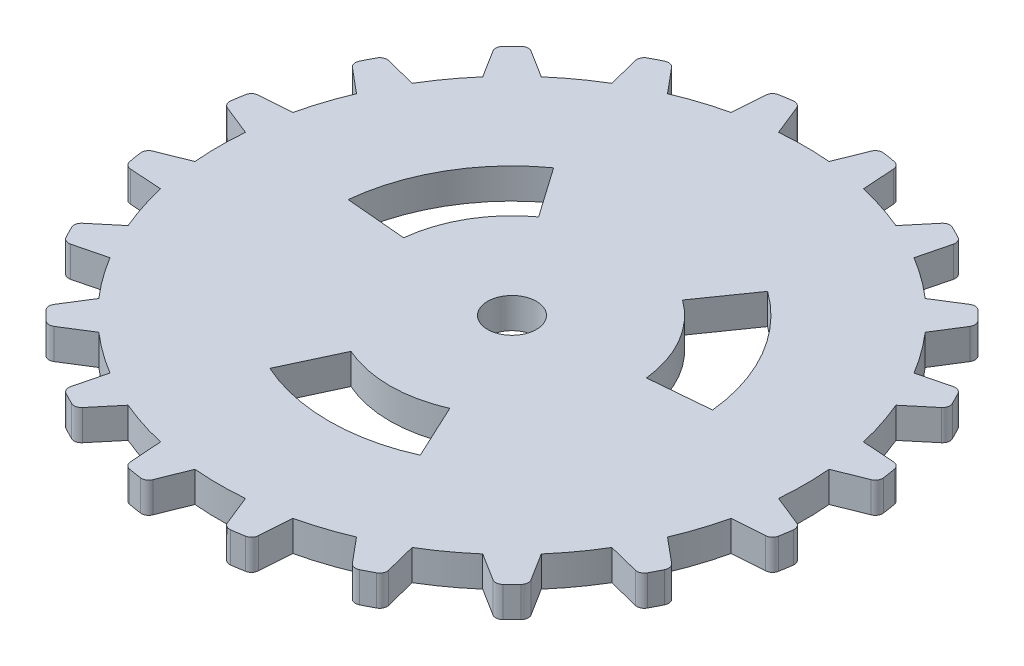
from build123d import *

# Parameters (mm, degrees)
BOSS_EXTRUDE1_DEPTH = 2.5
FILLET1_R           = 0.6
SKETCH3_R           = 2
CUT_EXTRUDE2_DEPTH  = 3.5
CUT_EXTRUDE3_DEPTH  = 10


with BuildPart() as part:
    # Sketch1 → Boss-Extrude1 (new body)
    with BuildSketch(Plane(origin=(0, 0, 0), x_dir=(1, 0, 0), z_dir=(0, 1, 0))):
        with BuildLine():
            Line((-2.069685574, 23.903244449), (-3.232226288, 26.798460531))
            ThreePointArc((-3.232226288, 26.798460531), (-4.222590109, 26.66035458), (-5.207159099, 26.485661549))
            Line((-5.207159099, 26.485661549), (-5.418128963, 23.372902518))
            ThreePointArc((-5.418128963, 23.372902518), (-7.414149843, 22.818393363), (-9.354896707, 22.093768379))
            Line((-9.354896707, 22.093768379), (-11.3552096, 24.488037662))
            ThreePointArc((-11.3552096, 24.488037662), (-12.25442448, 24.050651847), (-13.136822119, 23.580260351))
            Line((-13.136822119, 23.580260351), (-12.375570942, 20.554657318))
            ThreePointArc((-12.375570942, 20.554657318), (-14.102546855, 19.410483399), (-15.724385372, 18.121600323))
            Line((-15.724385372, 18.121600323), (-18.36666588, 19.780555048))
            ThreePointArc((-18.36666588, 19.780555048), (-19.086710402, 19.086703739), (-19.78056146, 18.366658976))
            Line((-19.78056146, 18.366658976), (-18.121605812, 15.724379046))
            ThreePointArc((-18.121605812, 15.724379046), (-19.410488322, 14.102540079), (-20.554661637, 12.375563767))
            Line((-20.554661637, 12.375563767), (-23.580264936, 13.136813888))
            ThreePointArc((-23.580264936, 13.136813888), (-24.050656124, 12.254416085), (-24.488041625, 11.355201052))
            Line((-24.488041625, 11.355201052), (-22.093771644, 9.354888995))
            ThreePointArc((-22.093771644, 9.354888995), (-22.818395951, 7.414141878), (-23.37290441, 5.418120804))
            Line((-23.37290441, 5.418120804), (-26.485663367, 5.207149854))
            ThreePointArc((-26.485663367, 5.207149854), (-26.660356054, 4.222580803), (-26.798461659, 3.232216933))
            Line((-26.798461659, 3.232216933), (-23.903245172, 2.06967723))
            ThreePointArc((-23.903245172, 2.06967723), (-23.99268, -4.188e-06), (-23.903244449, -2.069685574))
            Line((-23.903244449, -2.069685574), (-26.798460531, -3.232226288))
            ThreePointArc((-26.798460531, -3.232226288), (-26.66035458, -4.222590109), (-26.485661549, -5.207159099))
            Line((-26.485661549, -5.207159099), (-23.372902518, -5.418128963))
            ThreePointArc((-23.372902518, -5.418128963), (-22.818393363, -7.414149843), (-22.093768379, -9.354896707))
            Line((-22.093768379, -9.354896707), (-24.488037662, -11.3552096))
            ThreePointArc((-24.488037662, -11.3552096), (-24.050651847, -12.25442448), (-23.580260351, -13.136822119))
            Line((-23.580260351, -13.136822119), (-20.554657318, -12.375570942))
            ThreePointArc((-20.554657318, -12.375570942), (-19.410483399, -14.102546855), (-18.121600323, -15.724385372))
            Line((-18.121600323, -15.724385372), (-19.780555048, -18.36666588))
            ThreePointArc((-19.780555048, -18.36666588), (-19.086703739, -19.086710402), (-18.366658976, -19.78056146))
            Line((-18.366658976, -19.78056146), (-15.724379046, -18.121605812))
            ThreePointArc((-15.724379046, -18.121605812), (-14.102540079, -19.410488322), (-12.375563767, -20.554661637))
            Line((-12.375563767, -20.554661637), (-13.136813888, -23.580264936))
            ThreePointArc((-13.136813888, -23.580264936), (-12.254416085, -24.050656124), (-11.355201052, -24.488041625))
            Line((-11.355201052, -24.488041625), (-9.354888995, -22.093771644))
            ThreePointArc((-9.354888995, -22.093771644), (-7.414141878, -22.818395951), (-5.418120804, -23.37290441))
            Line((-5.418120804, -23.37290441), (-5.207149854, -26.485663367))
            ThreePointArc((-5.207149854, -26.485663367), (-4.222580803, -26.660356054), (-3.232216933, -26.798461659))
            Line((-3.232216933, -26.798461659), (-2.06967723, -23.903245172))
            ThreePointArc((-2.06967723, -23.903245172), (4.188e-06, -23.99268), (2.069685574, -23.903244449))
            Line((2.069685574, -23.903244449), (3.232226288, -26.798460531))
            ThreePointArc((3.232226288, -26.798460531), (4.222590109, -26.66035458), (5.207159099, -26.485661549))
            Line((5.207159099, -26.485661549), (5.418128963, -23.372902518))
            ThreePointArc((5.418128963, -23.372902518), (7.414149843, -22.818393363), (9.354896707, -22.093768379))
            Line((9.354896707, -22.093768379), (11.3552096, -24.488037662))
            ThreePointArc((11.3552096, -24.488037662), (12.25442448, -24.050651847), (13.136822119, -23.580260351))
            Line((13.136822119, -23.580260351), (12.375570942, -20.554657318))
            ThreePointArc((12.375570942, -20.554657318), (14.102546855, -19.410483399), (15.724385372, -18.121600323))
            Line((15.724385372, -18.121600323), (18.36666588, -19.780555048))
            ThreePointArc((18.36666588, -19.780555048), (19.086710402, -19.086703739), (19.78056146, -18.366658976))
            Line((19.78056146, -18.366658976), (18.121605812, -15.724379046))
            ThreePointArc((18.121605812, -15.724379046), (19.410488322, -14.102540079), (20.554661637, -12.375563767))
            Line((20.554661637, -12.375563767), (23.580264936, -13.136813888))
            ThreePointArc((23.580264936, -13.136813888), (24.050656124, -12.254416085), (24.488041625, -11.355201052))
            Line((24.488041625, -11.355201052), (22.093771644, -9.354888995))
            ThreePointArc((22.093771644, -9.354888995), (22.818395951, -7.414141878), (23.37290441, -5.418120804))
            Line((23.37290441, -5.418120804), (26.485663367, -5.207149854))
            ThreePointArc((26.485663367, -5.207149854), (26.660356054, -4.222580803), (26.798461659, -3.232216933))
            Line((26.798461659, -3.232216933), (23.903245172, -2.06967723))
            ThreePointArc((23.903245172, -2.06967723), (23.99268, 4.188e-06), (23.903244449, 2.069685574))
            Line((23.903244449, 2.069685574), (26.798460531, 3.232226288))
            ThreePointArc((26.798460531, 3.232226288), (26.66035458, 4.222590109), (26.485661549, 5.207159099))
            Line((26.485661549, 5.207159099), (23.372902518, 5.418128963))
            ThreePointArc((23.372902518, 5.418128963), (22.818393363, 7.414149843), (22.093768379, 9.354896707))
            Line((22.093768379, 9.354896707), (24.488037662, 11.3552096))
            ThreePointArc((24.488037662, 11.3552096), (24.050651847, 12.25442448), (23.580260351, 13.136822119))
            Line((23.580260351, 13.136822119), (20.554657318, 12.375570942))
            ThreePointArc((20.554657318, 12.375570942), (19.410483399, 14.102546855), (18.121600323, 15.724385372))
            Line((18.121600323, 15.724385372), (19.780555048, 18.36666588))
            ThreePointArc((19.780555048, 18.36666588), (19.086703739, 19.086710402), (18.366658976, 19.78056146))
            Line((18.366658976, 19.78056146), (15.724379046, 18.121605812))
            ThreePointArc((15.724379046, 18.121605812), (14.102540079, 19.410488322), (12.375563767, 20.554661637))
            Line((12.375563767, 20.554661637), (13.136813888, 23.580264936))
            ThreePointArc((13.136813888, 23.580264936), (12.254416085, 24.050656124), (11.355201052, 24.488041625))
            Line((11.355201052, 24.488041625), (9.354888995, 22.093771644))
            ThreePointArc((9.354888995, 22.093771644), (7.414141878, 22.818395951), (5.418120804, 23.37290441))
            Line((5.418120804, 23.37290441), (5.207149854, 26.485663367))
            ThreePointArc((5.207149854, 26.485663367), (4.222580803, 26.660356054), (3.232216933, 26.798461659))
            Line((3.232216933, 26.798461659), (2.06967723, 23.903245172))
            ThreePointArc((2.06967723, 23.903245172), (-4.188e-06, 23.99268), (-2.069685574, 23.903244449))
        make_face()
    extrude(amount=-BOSS_EXTRUDE1_DEPTH)

    # Fillet1
    fillet1_edges = [part.edges().sort_by_distance(p)[0] for p in [
        (3.232216933, -1.25, -26.798461659),
        (5.207149854, -1.25, -26.485663367),
        (11.355201052, -1.25, -24.488041625),
        (13.136813888, -1.25, -23.580264936),
        (18.366658976, -1.25, -19.78056146),
        (19.780555048, -1.25, -18.36666588),
        (23.580260351, -1.25, -13.136822119),
        (24.488037662, -1.25, -11.3552096),
        (26.485661549, -1.25, -5.207159099),
        (26.798460531, -1.25, -3.232226288),
        (26.798461659, -1.25, 3.232216933),
        (26.485663367, -1.25, 5.207149854),
        (24.488041625, -1.25, 11.355201052),
        (23.580264936, -1.25, 13.136813888),
        (19.78056146, -1.25, 18.366658976),
        (18.36666588, -1.25, 19.780555048),
        (13.136822119, -1.25, 23.580260351),
        (11.3552096, -1.25, 24.488037662),
        (5.207159099, -1.25, 26.485661549),
        (3.232226288, -1.25, 26.798460531),
        (-3.232216933, -1.25, 26.798461659),
        (-5.207149854, -1.25, 26.485663367),
        (-11.355201052, -1.25, 24.488041625),
        (-13.136813888, -1.25, 23.580264936),
        (-18.366658976, -1.25, 19.78056146),
        (-19.780555048, -1.25, 18.36666588),
        (-23.580260351, -1.25, 13.136822119),
        (-24.488037662, -1.25, 11.3552096),
        (-26.485661549, -1.25, 5.207159099),
        (-26.798460531, -1.25, 3.232226288),
        (-26.798461659, -1.25, -3.232216933),
        (-26.485663367, -1.25, -5.207149854),
        (-24.488041625, -1.25, -11.355201052),
        (-23.580264936, -1.25, -13.136813888),
        (-19.78056146, -1.25, -18.366658976),
        (-18.36666588, -1.25, -19.780555048),
        (-13.136822119, -1.25, -23.580260351),
        (-11.3552096, -1.25, -24.488037662),
        (-5.207159099, -1.25, -26.485661549),
        (-3.232226288, -1.25, -26.798460531),
    ]]
    fillet(fillet1_edges, radius=FILLET1_R)

    # Sketch3 → Cut-Extrude2 (cut, through all)
    with BuildSketch(Plane.XZ.offset(2.5)):
        Circle(SKETCH3_R)
    extrude(amount=-CUT_EXTRUDE2_DEPTH, mode=Mode.SUBTRACT)

    # Sketch4 → Cut-Extrude3 (cut)
    with BuildSketch(Plane(origin=(0, 0, 0), x_dir=(1, 0, 0), z_dir=(0, 1, 0))):
        with BuildLine():
            Line((5.895358209, 8.077422335), (8.763608366, 12.17370808))
            ThreePointArc((8.763608366, 12.17370808), (12.990381057, 7.5), (14.924544638, 1.502653434))
            Line((14.924544638, 1.502653434), (9.942932044, 1.066818806))
            ThreePointArc((9.942932044, 1.066818806), (8.660254038, 5), (5.895358209, 8.077422335))
        make_face()
        with BuildLine():
            Line((4.047573835, -9.144241141), (6.160936272, -13.676361514))
            ThreePointArc((6.160936272, -13.676361514), (0, -15), (-6.160936272, -13.676361514))
            Line((-6.160936272, -13.676361514), (-4.047573835, -9.144241141))
            ThreePointArc((-4.047573835, -9.144241141), (0, -10), (4.047573835, -9.144241141))
        make_face()
        with BuildLine():
            Line((-9.942932044, 1.066818806), (-14.924544638, 1.502653434))
            ThreePointArc((-14.924544638, 1.502653434), (-12.990381057, 7.5), (-8.763608366, 12.17370808))
            Line((-8.763608366, 12.17370808), (-5.895358209, 8.077422335))
            ThreePointArc((-5.895358209, 8.077422335), (-8.660254038, 5), (-9.942932044, 1.066818806))
        make_face()
    extrude(amount=-CUT_EXTRUDE3_DEPTH, mode=Mode.SUBTRACT)


solid = part.part
